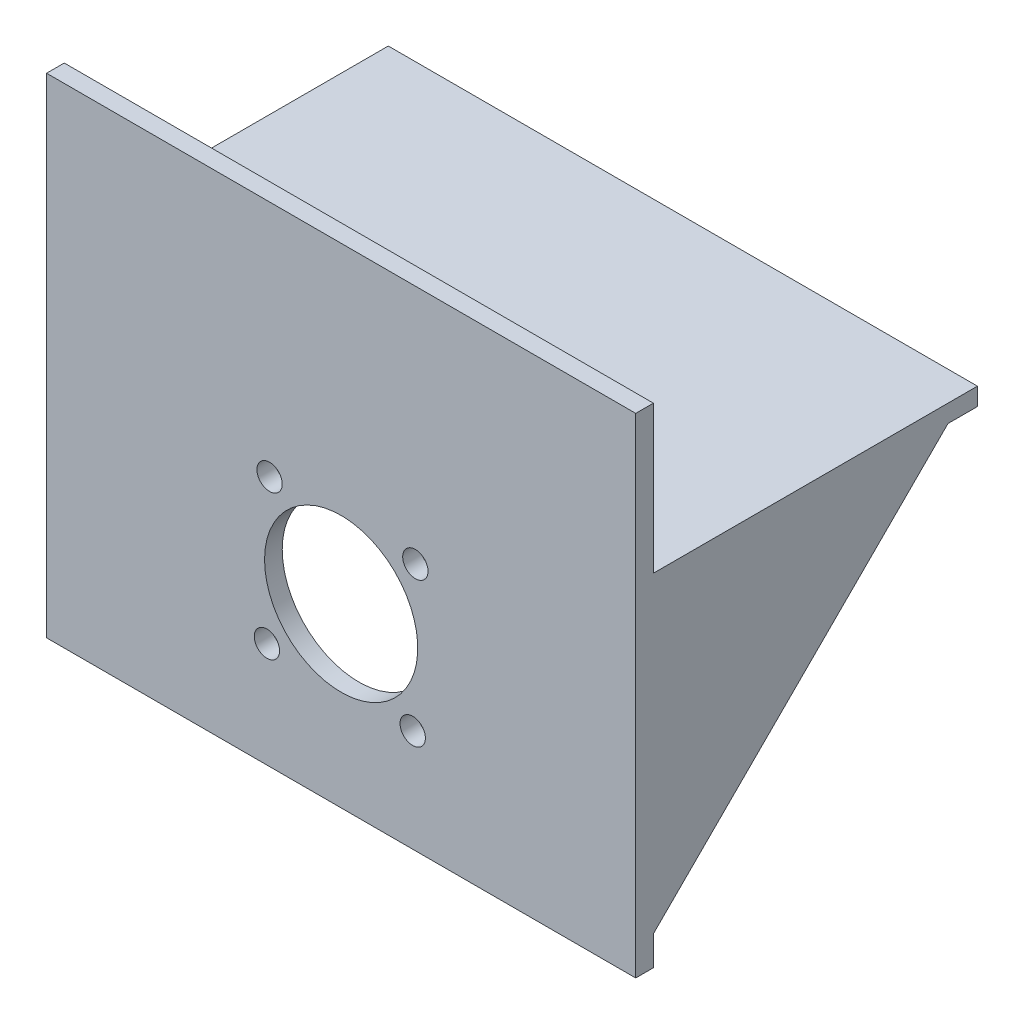
from build123d import *

# Parameters (mm, degrees)
SKETCH1_W           = 100
SKETCH1_H           = 55
BOSS_EXTRUDE1_DEPTH = 3
SKETCH2_W           = 100
SKETCH2_H           = 83
BOSS_EXTRUDE2_DEPTH = 3
BOSS_EXTRUDE3_DEPTH = 3
BOSS_EXTRUDE4_DEPTH = 3
SKETCH5_R           = 13
SKETCH5_R_2         = 2.15
CUT_EXTRUDE1_DEPTH  = 4


with BuildPart() as part:
    # Sketch1 → Boss-Extrude1 (new body)
    with BuildSketch(Plane(origin=(0, 0, 0), x_dir=(1, 0, 0), z_dir=(0, 1, 0))):
        Rectangle(SKETCH1_W, SKETCH1_H)
    extrude(amount=BOSS_EXTRUDE1_DEPTH)

    # Sketch2 → Boss-Extrude2 (add)
    with BuildSketch(Plane.XY.offset(27.5)):
        with Locations((0, -13.5)):
            Rectangle(SKETCH2_W, SKETCH2_H)
    extrude(amount=BOSS_EXTRUDE2_DEPTH)

    # Sketch3 → Boss-Extrude3 (add)
    with BuildSketch(Plane(origin=(50, 0, 0), x_dir=(0, 0, -1), z_dir=(1, 0, 0))):
        Polygon((-27.5, 0), (22.5, 0), (-27.5, -50), align=None)
    extrude(amount=-BOSS_EXTRUDE3_DEPTH)

    # Sketch4 → Boss-Extrude4 (add)
    with BuildSketch(Plane.ZY.offset(50)):
        Polygon((27.5, 0), (27.5, -50), (-22.5, 0), align=None)
    extrude(amount=-BOSS_EXTRUDE4_DEPTH)

    # Sketch5 → Cut-Extrude1 (cut, through all)
    with BuildSketch(Plane(origin=(0, 0, 27.5), x_dir=(-1, 0, 0), z_dir=(0, 0, -1))):
        with Locations((0, -25)):
            Circle(SKETCH5_R)
        with Locations((12.148789351, -12.404091248)):
            Circle(SKETCH5_R_2)
        with Locations((12.595908752, -37.148789351)):
            Circle(SKETCH5_R_2)
        with Locations((-12.148789351, -37.595908752)):
            Circle(SKETCH5_R_2)
        with Locations((-12.595908752, -12.851210649)):
            Circle(SKETCH5_R_2)
    extrude(amount=-CUT_EXTRUDE1_DEPTH, mode=Mode.SUBTRACT)


solid = part.part
